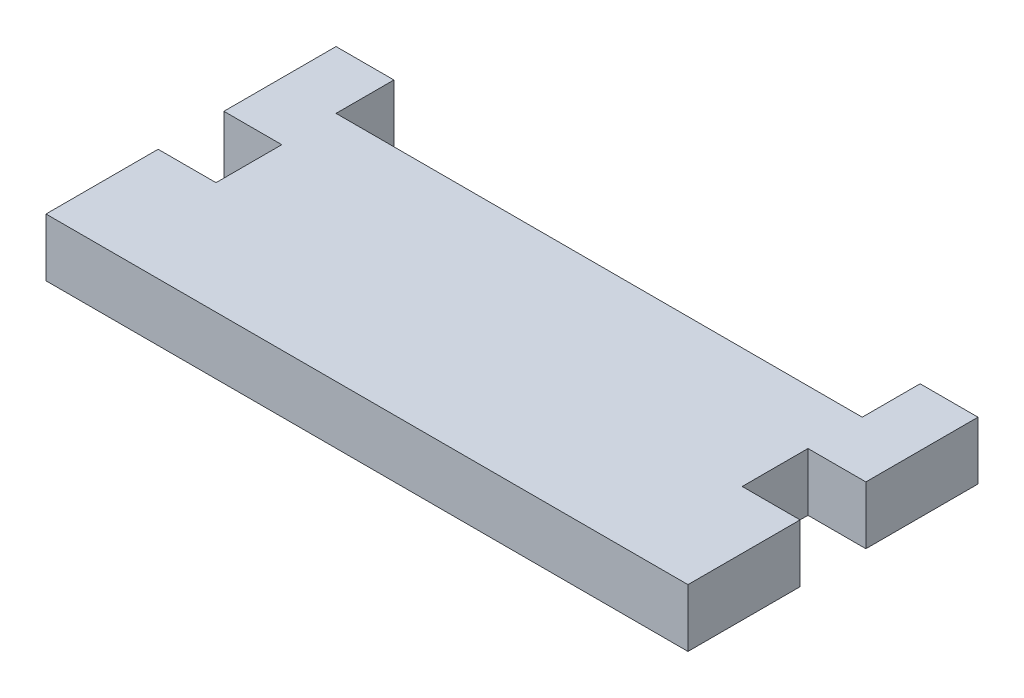
from build123d import *

# Parameters (mm, degrees)
BOSS_EXTRUDE1_DEPTH = 5.588


with BuildPart() as part:
    # Sketch1 → Boss-Extrude1 (new body)
    with BuildSketch(Plane(origin=(0, 0, 0), x_dir=(1, 0, 0), z_dir=(0, 1, 0))):
        Polygon((-25.4, 14), (-30.988, 14), (-30.988, 3.175), (-25.4, 3.175), (-25.4, -3.175), (-30.988, -3.175), (-30.988, -14), (30.988, -14), (30.988, -3.175), (25.4, -3.175), (25.4, 3.175), (30.988, 3.175), (30.988, 14), (25.4, 14), (25.4, 8.412), (-25.4, 8.412), align=None)
    extrude(amount=BOSS_EXTRUDE1_DEPTH)


solid = part.part
